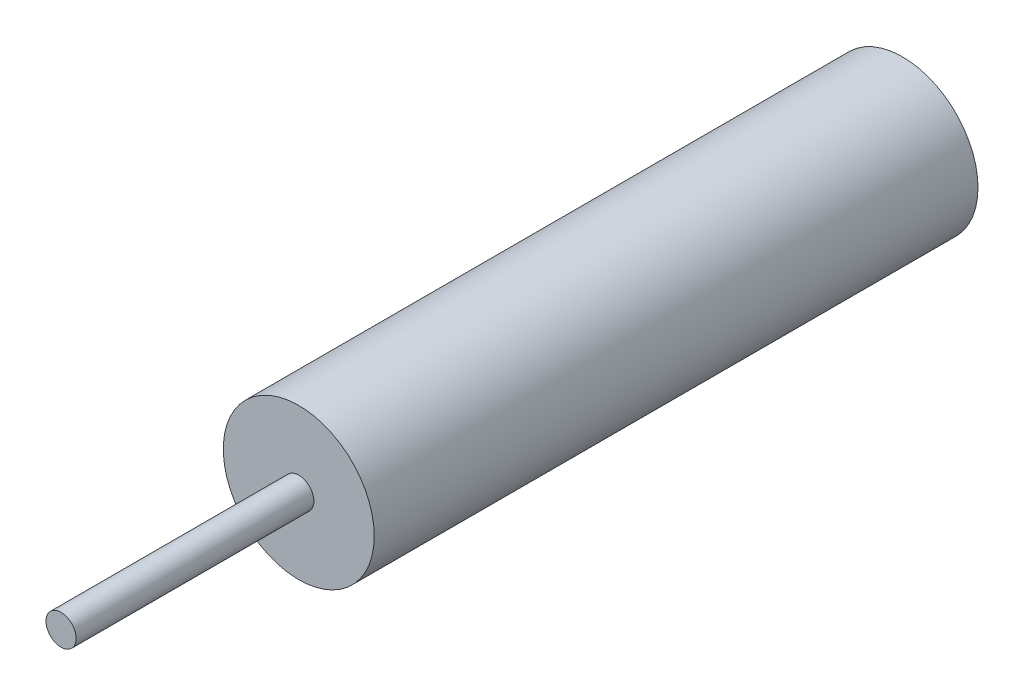
from build123d import *

# Parameters (mm, degrees)
SKETCH1_R           = 3.175
BOSS_EXTRUDE1_DEPTH = 25.4
SKETCH2_R           = 0.635
BOSS_EXTRUDE2_DEPTH = 10


with BuildPart() as part:
    # Sketch1 → Boss-Extrude1 (new body)
    with BuildSketch(Plane.XY):
        Circle(SKETCH1_R)
    extrude(amount=BOSS_EXTRUDE1_DEPTH)

    # Sketch2 → Boss-Extrude2 (add)
    with BuildSketch(Plane.XY.offset(25.4)):
        Circle(SKETCH2_R)
    extrude(amount=BOSS_EXTRUDE2_DEPTH)


solid = part.part
